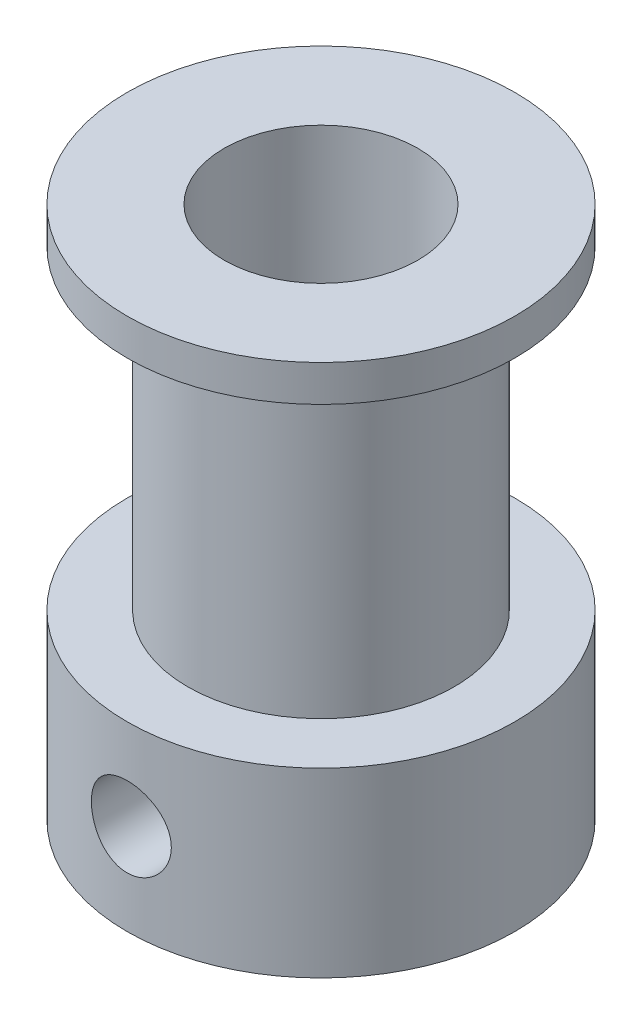
from build123d import *

# Parameters (mm, degrees)
CROQUIS1_R              = 8
SALIENTE_EXTRUIR1_DEPTH = 7.5
CROQUIS2_R              = 5.5
SALIENTE_EXTRUIR2_DEPTH = 13
CROQUIS3_R              = 8
SALIENTE_EXTRUIR3_DEPTH = 1.5
CROQUIS4_R              = 4
CORTAR_EXTRUIR1_DEPTH   = 23
CROQUIS6_W              = 1.65
CROQUIS6_H              = 8.001
MATRIZC1_COUNT          = 2
MATRIZC1_ANGLE          = 90


with BuildPart() as part:
    # Croquis1 → Saliente-Extruir1 (new body)
    with BuildSketch(Plane(origin=(0, 0, 0), x_dir=(1, 0, 0), z_dir=(0, 1, 0))):
        Circle(CROQUIS1_R)
    extrude(amount=SALIENTE_EXTRUIR1_DEPTH)

    # Croquis2 → Saliente-Extruir2 (add)
    with BuildSketch(Plane(origin=(0, 7.5, 0), x_dir=(1, 0, 0), z_dir=(0, 1, 0))):
        Circle(CROQUIS2_R)
    extrude(amount=SALIENTE_EXTRUIR2_DEPTH)

    # Croquis3 → Saliente-Extruir3 (add)
    with BuildSketch(Plane(origin=(0, 20.5, 0), x_dir=(1, 0, 0), z_dir=(0, 1, 0))):
        Circle(CROQUIS3_R)
    extrude(amount=SALIENTE_EXTRUIR3_DEPTH)

    # Croquis4 → Cortar-Extruir1 (cut, through all)
    with BuildSketch(Plane(origin=(0, 22, 0), x_dir=(1, 0, 0), z_dir=(0, 1, 0))):
        Circle(CROQUIS4_R)
    extrude(amount=-CORTAR_EXTRUIR1_DEPTH, mode=Mode.SUBTRACT)

    # Croquis6 → Taladro roscado M41 (falta definir posicio) (revolve, cut)
    with BuildSketch(Plane(origin=(0, 3.75, 0), x_dir=(0, 1, 0), z_dir=(1, 0, 0))):
        with Locations((0.825, 4.0005)):
            Rectangle(CROQUIS6_W, CROQUIS6_H)
    taladro_roscado_m41_falta_definir_posic = revolve(axis=Axis((0, 3.75, -6.35), (0, 0, 1)), mode=Mode.SUBTRACT)

    # MatrizC1: Taladro roscado M41 (falta definir posicio) ×2 about axis
    matrizc1_axis = Axis((0, 7.5, 0), (0, -1, 0))
    for i in range(1, MATRIZC1_COUNT):
        add(taladro_roscado_m41_falta_definir_posic.rotate(matrizc1_axis, i * MATRIZC1_ANGLE / (MATRIZC1_COUNT - 1)), mode=Mode.SUBTRACT)


solid = part.part
